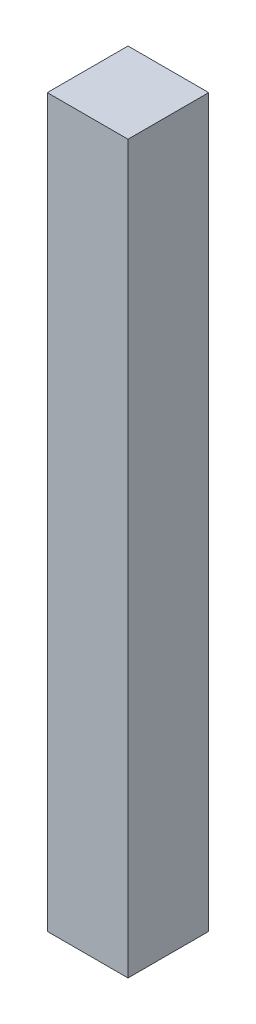
from build123d import *

# Parameters (mm, degrees)
ESQUISSE1_W        = 20
ESQUISSE1_H        = 20
BOSS_EXTRU_1_DEPTH = 180


with BuildPart() as part:
    # Esquisse1 → Boss.-Extru.1 (new body)
    with BuildSketch(Plane(origin=(0, 0, 0), x_dir=(1, 0, 0), z_dir=(0, 1, 0))):
        with Locations((-10, 10)):
            Rectangle(ESQUISSE1_W, ESQUISSE1_H)
    extrude(amount=BOSS_EXTRU_1_DEPTH)


solid = part.part
